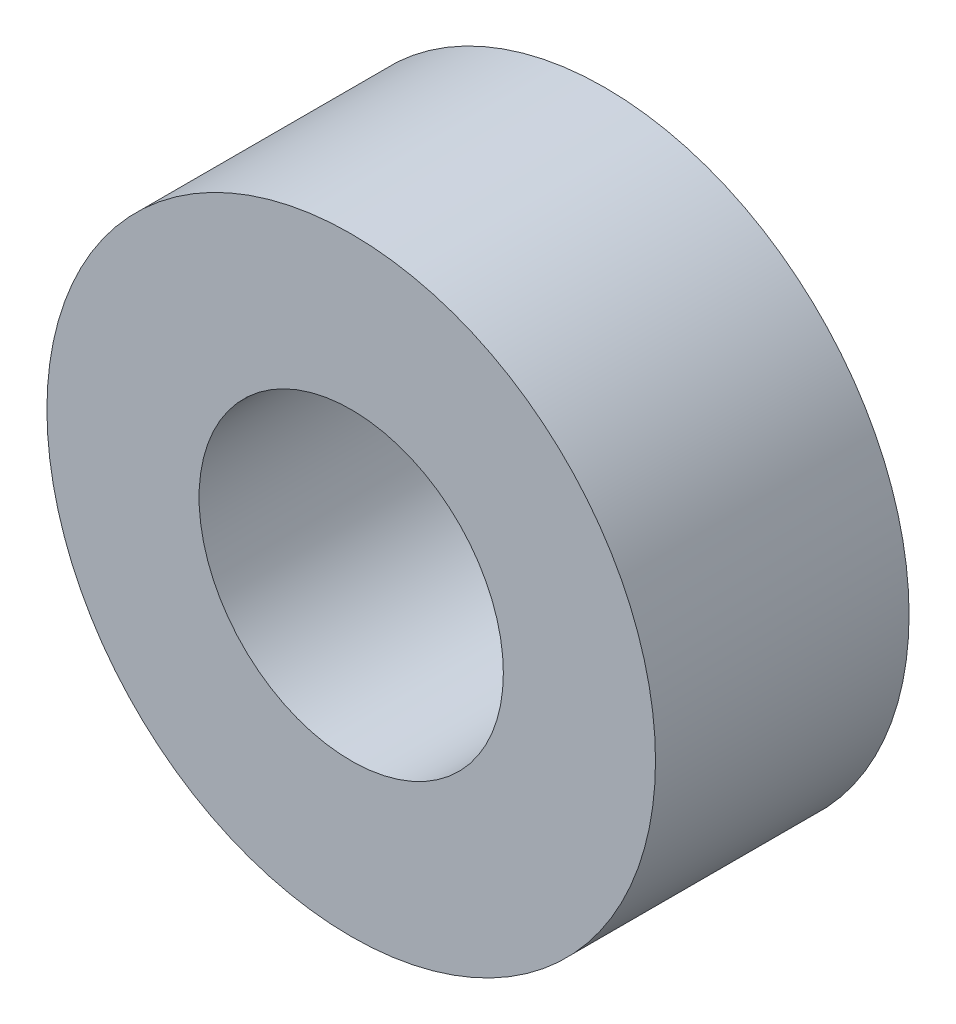
from build123d import *

# Parameters (mm, degrees)
SKETCH1_R           = 3
SKETCH1_R_2         = 1.5
BOSS_EXTRUDE1_DEPTH = 2.5


with BuildPart() as part:
    # Sketch1 → Boss-Extrude1 (new body)
    with BuildSketch(Plane.XY):
        Circle(SKETCH1_R)
        Circle(SKETCH1_R_2, mode=Mode.SUBTRACT)
    extrude(amount=BOSS_EXTRUDE1_DEPTH)


solid = part.part
